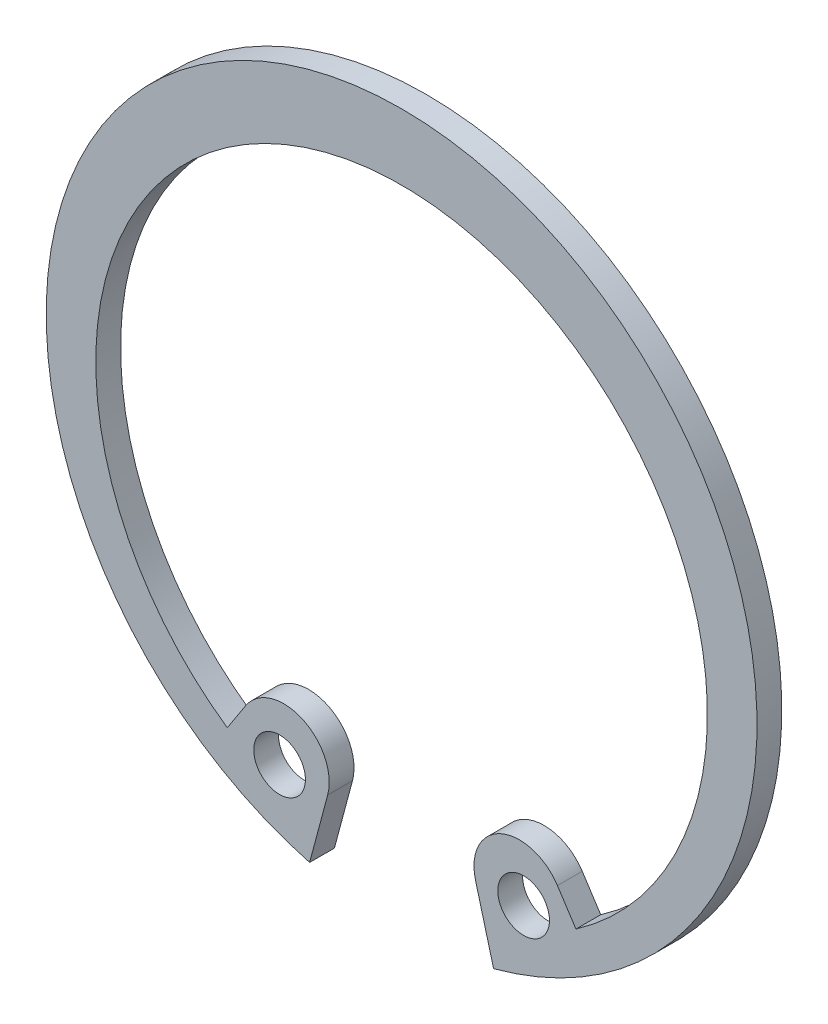
from build123d import *

# Parameters (mm, degrees)
SKETCH2_R           = 1.25
BOSS_EXTRUDE1_DEPTH = 1.2
FILLET1_R           = 2.197241


with BuildPart() as part:
    # Sketch2 → Boss-Extrude1 (new body)
    with BuildSketch(Plane.XY):
        with BuildLine():
            Line((6.518417516, -10.013392411), (8.436546126, -12.95996256))
            ThreePointArc((8.436546126, -12.95996256), (14.124578682, 3.619986092), (0, 14))
            Line((0, 14), (0, 17.2))
            ThreePointArc((0, 17.2), (17.052851616, 2.245050506), (4.451687576, -16.613924212))
            Line((4.451687576, -16.613924212), (3.092403424, -11.541006696))
            Line((3.092403424, -11.541006696), (6.518417516, -10.013392411))
        make_face()
        with Locations((5.904953543, -13.243168943)):
            Circle(SKETCH2_R, mode=Mode.SUBTRACT)
    extrude(amount=BOSS_EXTRUDE1_DEPTH)

    # Fillet1
    fillet1_edges = [part.edges().sort_by_distance(p)[0] for p in [
        (6.518417516, -10.013392411, 0.6),
        (3.092403424, -11.541006696, 0.6),
    ]]
    fillet(fillet1_edges, radius=FILLET1_R)

    # Mirror1: part across plane


with BuildPart() as part_1:
    add(part.part)
    add(part.part.mirror(Plane(origin=(0, 17.2, 1.2), x_dir=(0, 0, 1), z_dir=(1, 0, 0))))


solid = part_1.part
